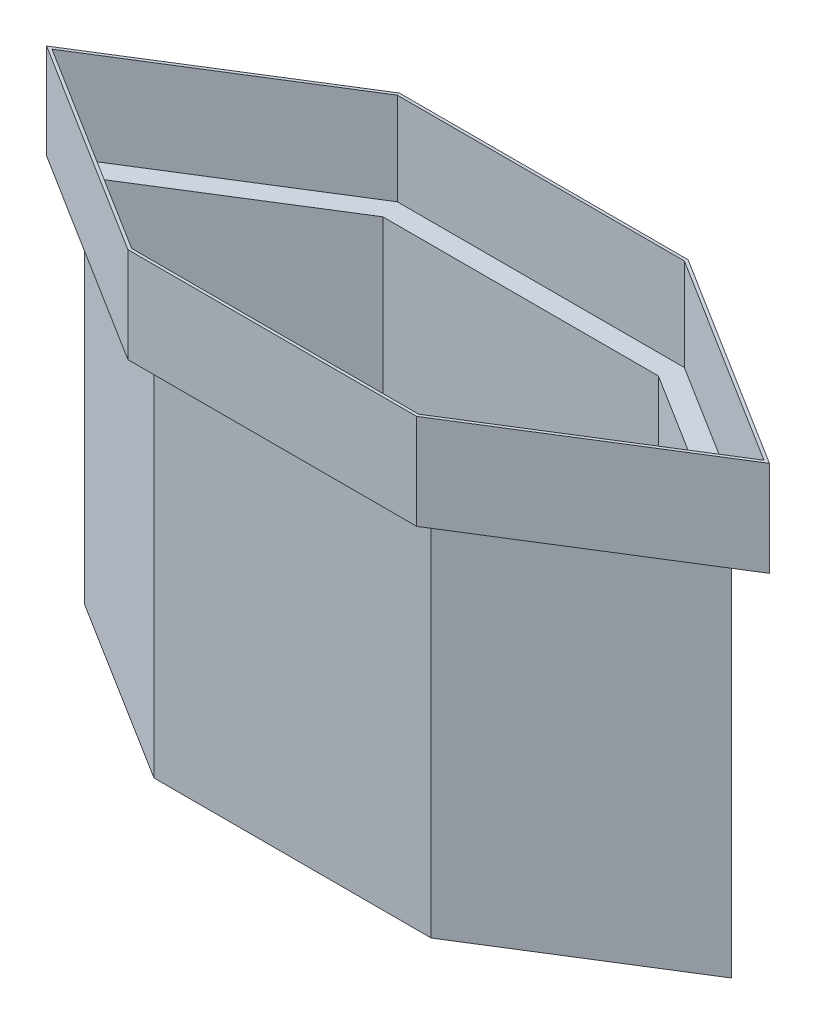
from build123d import *

# Parameters (mm, degrees)
BOSS_EXTRUDE1_DEPTH = 3.175
BOSS_EXTRUDE2_DEPTH = 403.225
BOSS_EXTRUDE3_DEPTH = 3.175
BOSS_EXTRUDE4_DEPTH = 101.6


with BuildPart() as part:
    # Sketch2 → Boss-Extrude1 (new body)
    with BuildSketch(Plane(origin=(0, 0, 0), x_dir=(1, 0, 0), z_dir=(0, 1, 0))):
        Polygon((-152.4, 127), (-355.6, 0), (-152.4, -127), (152.4, -127), (355.6, 0), (152.4, 127), align=None)
    extrude(amount=BOSS_EXTRUDE1_DEPTH)

    # Sketch3 → Boss-Extrude2 (add)
    with BuildSketch(Plane(origin=(0, 3.175, 0), x_dir=(1, 0, 0), z_dir=(0, 1, 0))):
        Polygon((152.4, -127), (355.6, 0), (152.4, 127), (-152.4, 127), (-355.6, 0), (-152.4, -127), align=None)
        Polygon((151.489421981, -123.825), (349.609421981, 0), (151.489421981, 123.825), (-151.489421981, 123.825), (-349.609421981, 0), (-151.489421981, -123.825), align=None, mode=Mode.SUBTRACT)
    extrude(amount=BOSS_EXTRUDE2_DEPTH)

    # Sketch5 → Boss-Extrude3 (add)
    with BuildSketch(Plane(origin=(0, 406.4, 0), x_dir=(1, 0, 0), z_dir=(0, 1, 0))):
        Polygon((158.774046132, 149.225), (-158.774046132, 149.225), (-397.534046132, 0), (-158.774046132, -149.225), (158.774046132, -149.225), (397.534046132, 0), align=None)
        Polygon((151.489421981, 123.825), (-151.489421981, 123.825), (-349.609421981, 0), (-151.489421981, -123.825), (151.489421981, -123.825), (349.609421981, 0), align=None, mode=Mode.SUBTRACT)
    extrude(amount=BOSS_EXTRUDE3_DEPTH)

    # Sketch6 → Boss-Extrude4 (add)
    with BuildSketch(Plane(origin=(0, 409.575, 0), x_dir=(1, 0, 0), z_dir=(0, 1, 0))):
        Polygon((-158.774046132, 149.225), (-397.534046132, 0), (-158.774046132, -149.225), (158.774046132, -149.225), (397.534046132, 0), (158.774046132, 149.225), align=None)
        Polygon((-157.863468113, 146.05), (-391.543468113, 0), (-157.863468113, -146.05), (157.863468113, -146.05), (391.543468113, 0), (157.863468113, 146.05), align=None, mode=Mode.SUBTRACT)
    extrude(amount=BOSS_EXTRUDE4_DEPTH)


solid = part.part
